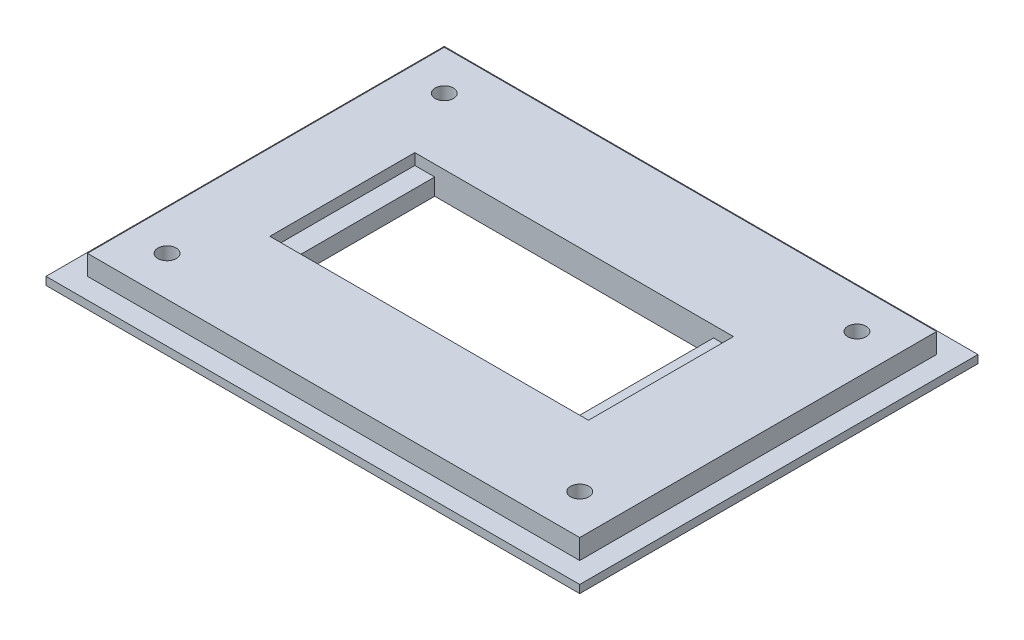
from build123d import *

# Parameters (mm, degrees)
SKETCH2_W           = 85.09
SKETCH2_H           = 63.5
BOSS_EXTRUDE1_DEPTH = 1.27
SKETCH3_W           = 78.486
SKETCH3_H           = 56.896
BOSS_EXTRUDE2_DEPTH = 3.175
SKETCH4_W           = 50.8
SKETCH4_H           = 23.114
CUT_EXTRUDE1_DEPTH  = 1.778
SKETCH5_W           = 44.45
SKETCH5_H           = 23.114
CUT_EXTRUDE2_DEPTH  = 3.667
SKETCH6_R           = 1.4605
CUT_EXTRUDE3_DEPTH  = 5.445


with BuildPart() as part:
    # Sketch2 → Boss-Extrude1 (new body)
    with BuildSketch(Plane(origin=(0, 0, 0), x_dir=(1, 0, 0), z_dir=(0, 1, 0))):
        with Locations((42.545, 31.75)):
            Rectangle(SKETCH2_W, SKETCH2_H)
    extrude(amount=BOSS_EXTRUDE1_DEPTH)

    # Sketch3 → Boss-Extrude2 (add)
    with BuildSketch(Plane(origin=(0, 1.27, 0), x_dir=(1, 0, 0), z_dir=(0, 1, 0))):
        with Locations((42.545, 31.75)):
            Rectangle(SKETCH3_W, SKETCH3_H)
    extrude(amount=BOSS_EXTRUDE2_DEPTH)

    # Sketch4 → Cut-Extrude1 (cut)
    with BuildSketch(Plane(origin=(0, 4.445, 0), x_dir=(1, 0, 0), z_dir=(0, 1, 0))):
        with Locations((40.894, 31.75)):
            Rectangle(SKETCH4_W, SKETCH4_H)
    extrude(amount=-CUT_EXTRUDE1_DEPTH, mode=Mode.SUBTRACT)

    # Sketch5 → Cut-Extrude2 (cut, through all)
    with BuildSketch(Plane(origin=(0, 2.667, 0), x_dir=(1, 0, 0), z_dir=(0, 1, 0))):
        with Locations((40.894, 31.75)):
            Rectangle(SKETCH5_W, SKETCH5_H)
    extrude(amount=-CUT_EXTRUDE2_DEPTH, mode=Mode.SUBTRACT)

    # Sketch6 → Cut-Extrude3 (cut, through all)
    with BuildSketch(Plane(origin=(0, 4.445, 0), x_dir=(1, 0, 0), z_dir=(0, 1, 0))):
        with Locations((9.652, 53.848)):
            Circle(SKETCH6_R)
        with Locations((9.652, 9.652)):
            Circle(SKETCH6_R)
        with Locations((75.438, 53.848)):
            Circle(SKETCH6_R)
        with Locations((75.438, 9.652)):
            Circle(SKETCH6_R)
    extrude(amount=-CUT_EXTRUDE3_DEPTH, mode=Mode.SUBTRACT)


solid = part.part
